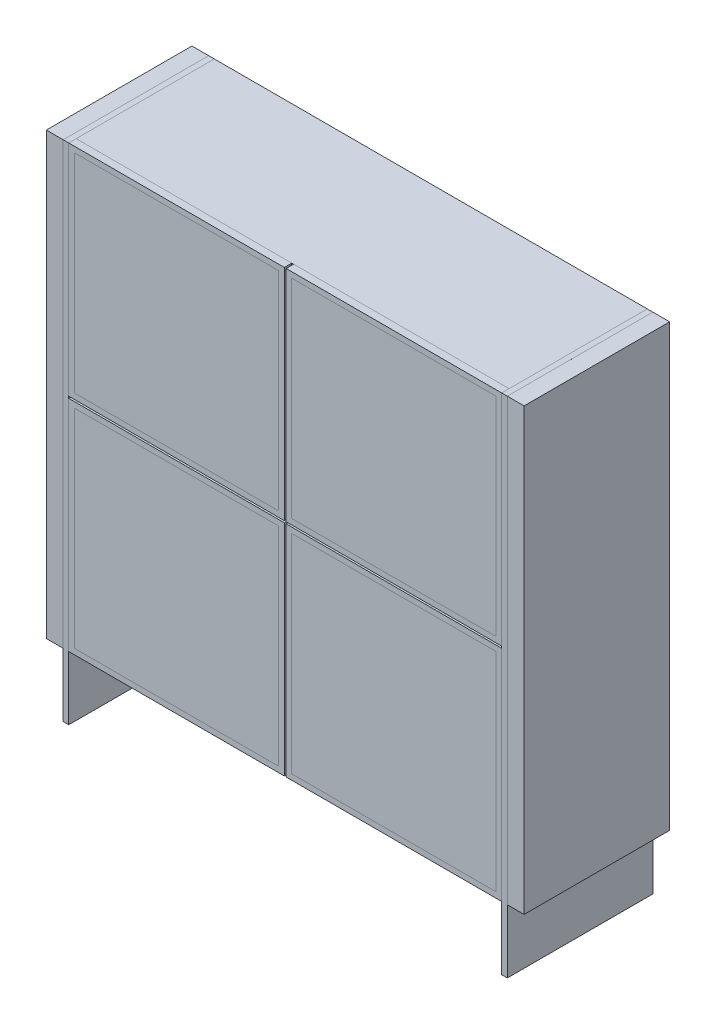
from build123d import *

# Parameters (mm, degrees)
CROQUIS1_W                     = 1160
CROQUIS1_H                     = 1180
SALIENTE_EXTRUIR1_DEPTH        = 370
VACIADO1_T                     = -10
CROQUIS1_4_W                   = 45
CROQUIS1_4_H                   = 1180
SALIENTE_EXTRUIR3_DEPTH        = 20
SALIENTE_EXTRUIR3_DEPTH_BACK   = 370
SALIENTE_EXTRUIR3_2_DEPTH      = 20
SALIENTE_EXTRUIR3_2_DEPTH_BACK = 370
CROQUIS2_W                     = 15
CROQUIS2_H                     = 1350
SALIENTE_EXTRUIR2_DEPTH        = 20
SALIENTE_EXTRUIR2_DEPTH_BACK   = 370
SALIENTE_EXTRUIR2_2_DEPTH      = 20
SALIENTE_EXTRUIR2_2_DEPTH_BACK = 370
CROQUIS3_W                     = 10
CROQUIS3_H                     = 1160
CROQUIS3_W_2                   = 1140
CROQUIS3_H_2                   = 10
SALIENTE_EXTRUIR4_DEPTH        = 360
SALIENTE_EXTRUIR5_START        = -20
CROQUIS4_W                     = 565
CROQUIS4_H                     = 10
SALIENTE_EXTRUIR5_DEPTH        = 340
SALIENTE_EXTRUIR5_2_DEPTH      = 340
SALIENTE_EXTRUIR5_3_DEPTH      = 340
SALIENTE_EXTRUIR5_4_DEPTH      = 340
CROQUIS5_W                     = 577.5
CROQUIS5_H                     = 587.5
CROQUIS5_W_2                   = 547.5
CROQUIS5_H_2                   = 557.5
SALIENTE_EXTRUIR6_DEPTH        = 20
SALIENTE_EXTRUIR6_2_DEPTH      = 20
SALIENTE_EXTRUIR6_3_DEPTH      = 20
SALIENTE_EXTRUIR6_4_DEPTH      = 20
SALIENTE_EXTRUIR7_START        = 10
CROQUIS5_2_W                   = 547.5
CROQUIS5_2_H                   = 557.5
SALIENTE_EXTRUIR7_DEPTH        = 10
SALIENTE_EXTRUIR7_2_DEPTH      = 10
SALIENTE_EXTRUIR7_3_DEPTH      = 10
SALIENTE_EXTRUIR7_4_DEPTH      = 10
CROQUIS6_W                     = 1160
CROQUIS6_H                     = 270
SALIENTE_EXTRUIR8_DEPTH        = 30


with BuildPart() as part:
    # Croquis1 → Saliente-Extruir1 (new body)
    with BuildSketch(Plane.XY):
        Rectangle(CROQUIS1_W, CROQUIS1_H)
    extrude(amount=-SALIENTE_EXTRUIR1_DEPTH)

    # Vaciado1
    vaciado1_openings = [part.faces().sort_by_distance(p)[0] for p in [
        (0, 0, 0),
    ]]
    offset(amount=VACIADO1_T, openings=vaciado1_openings, kind=Kind.INTERSECTION)


with BuildPart() as body_2:
    # Croquis1_4 → Saliente-Extruir3 (new body, two sides)
    with BuildSketch(Plane.XY) as saliente_extruir3_sk:
        with Locations((-617.5, 0)):
            Rectangle(CROQUIS1_4_W, CROQUIS1_4_H)
    extrude(amount=SALIENTE_EXTRUIR3_DEPTH)
    extrude(saliente_extruir3_sk.sketch, amount=-SALIENTE_EXTRUIR3_DEPTH_BACK)


with BuildPart() as body_3:
    # Croquis1_4 → Saliente-Extruir3 2 (new body, two sides)
    with BuildSketch(Plane.XY) as saliente_extruir3_2_sk:
        with Locations((617.5, 0)):
            Rectangle(CROQUIS1_4_W, CROQUIS1_4_H)
    extrude(amount=SALIENTE_EXTRUIR3_2_DEPTH)
    extrude(saliente_extruir3_2_sk.sketch, amount=-SALIENTE_EXTRUIR3_2_DEPTH_BACK)


with BuildPart() as body_4:
    # Croquis2 → Saliente-Extruir2 (new body, two sides)
    with BuildSketch(Plane.XY) as saliente_extruir2_sk:
        with Locations((-587.5, -85)):
            Rectangle(CROQUIS2_W, CROQUIS2_H)
    extrude(amount=SALIENTE_EXTRUIR2_DEPTH)
    extrude(saliente_extruir2_sk.sketch, amount=-SALIENTE_EXTRUIR2_DEPTH_BACK)


with BuildPart() as body_5:
    # Croquis2 → Saliente-Extruir2 2 (new body, two sides)
    with BuildSketch(Plane.XY) as saliente_extruir2_2_sk:
        with Locations((587.5, -85)):
            Rectangle(CROQUIS2_W, CROQUIS2_H)
    extrude(amount=SALIENTE_EXTRUIR2_2_DEPTH)
    extrude(saliente_extruir2_2_sk.sketch, amount=-SALIENTE_EXTRUIR2_2_DEPTH_BACK)


with BuildPart() as body_6:
    # Croquis3 → Saliente-Extruir4 (new body)
    with BuildSketch(Plane.XY):
        Rectangle(CROQUIS3_W, CROQUIS3_H)
        Rectangle(CROQUIS3_W_2, CROQUIS3_H_2)
    extrude(amount=-SALIENTE_EXTRUIR4_DEPTH)


with BuildPart() as body_7:
    # Croquis4 → Saliente-Extruir5 (new body)
    with BuildSketch(Plane.XY.offset(SALIENTE_EXTRUIR5_START)):
        with Locations((-287.5, 292.5)):
            Rectangle(CROQUIS4_W, CROQUIS4_H)
    extrude(amount=-SALIENTE_EXTRUIR5_DEPTH)


with BuildPart() as body_8:
    # Croquis4 → Saliente-Extruir5 2 (new body)
    with BuildSketch(Plane.XY.offset(SALIENTE_EXTRUIR5_START)):
        with Locations((287.5, 292.5)):
            Rectangle(CROQUIS4_W, CROQUIS4_H)
    extrude(amount=-SALIENTE_EXTRUIR5_2_DEPTH)


with BuildPart() as body_9:
    # Croquis4 → Saliente-Extruir5 3 (new body)
    with BuildSketch(Plane.XY.offset(SALIENTE_EXTRUIR5_START)):
        with Locations((287.5, -292.5)):
            Rectangle(CROQUIS4_W, CROQUIS4_H)
    extrude(amount=-SALIENTE_EXTRUIR5_3_DEPTH)


with BuildPart() as body_10:
    # Croquis4 → Saliente-Extruir5 4 (new body)
    with BuildSketch(Plane.XY.offset(SALIENTE_EXTRUIR5_START)):
        with Locations((-287.5, -292.5)):
            Rectangle(CROQUIS4_W, CROQUIS4_H)
    extrude(amount=-SALIENTE_EXTRUIR5_4_DEPTH)


with BuildPart() as body_11:
    # Croquis5 → Saliente-Extruir6 (new body)
    with BuildSketch(Plane.XY):
        with Locations((-291.25, -296.25)):
            Rectangle(CROQUIS5_W, CROQUIS5_H)
        with Locations((-291.25, -296.25)):
            Rectangle(CROQUIS5_W_2, CROQUIS5_H_2, mode=Mode.SUBTRACT)
    extrude(amount=SALIENTE_EXTRUIR6_DEPTH)


with BuildPart() as body_12:
    # Croquis5 → Saliente-Extruir6 2 (new body)
    with BuildSketch(Plane.XY):
        with Locations((-291.25, 296.25)):
            Rectangle(CROQUIS5_W, CROQUIS5_H)
        with Locations((-291.25, 296.25)):
            Rectangle(CROQUIS5_W_2, CROQUIS5_H_2, mode=Mode.SUBTRACT)
    extrude(amount=SALIENTE_EXTRUIR6_2_DEPTH)


with BuildPart() as body_13:
    # Croquis5 → Saliente-Extruir6 3 (new body)
    with BuildSketch(Plane.XY):
        with Locations((291.25, 296.25)):
            Rectangle(CROQUIS5_W, CROQUIS5_H)
        with Locations((291.25, 296.25)):
            Rectangle(CROQUIS5_W_2, CROQUIS5_H_2, mode=Mode.SUBTRACT)
    extrude(amount=SALIENTE_EXTRUIR6_3_DEPTH)


with BuildPart() as body_14:
    # Croquis5 → Saliente-Extruir6 4 (new body)
    with BuildSketch(Plane.XY):
        with Locations((291.25, -296.25)):
            Rectangle(CROQUIS5_W, CROQUIS5_H)
        with Locations((291.25, -296.25)):
            Rectangle(CROQUIS5_W_2, CROQUIS5_H_2, mode=Mode.SUBTRACT)
    extrude(amount=SALIENTE_EXTRUIR6_4_DEPTH)


with BuildPart() as body_15:
    # Croquis5_2 → Saliente-Extruir7 (new body)
    with BuildSketch(Plane.XY.offset(SALIENTE_EXTRUIR7_START)):
        with Locations((-291.25, 296.25)):
            Rectangle(CROQUIS5_2_W, CROQUIS5_2_H)
    extrude(amount=SALIENTE_EXTRUIR7_DEPTH)


with BuildPart() as body_16:
    # Croquis5_2 → Saliente-Extruir7 2 (new body)
    with BuildSketch(Plane.XY.offset(SALIENTE_EXTRUIR7_START)):
        with Locations((291.25, 296.25)):
            Rectangle(CROQUIS5_2_W, CROQUIS5_2_H)
    extrude(amount=SALIENTE_EXTRUIR7_2_DEPTH)


with BuildPart() as body_17:
    # Croquis5_2 → Saliente-Extruir7 3 (new body)
    with BuildSketch(Plane.XY.offset(SALIENTE_EXTRUIR7_START)):
        with Locations((-291.25, -296.25)):
            Rectangle(CROQUIS5_2_W, CROQUIS5_2_H)
    extrude(amount=SALIENTE_EXTRUIR7_3_DEPTH)


with BuildPart() as body_18:
    # Croquis5_2 → Saliente-Extruir7 4 (new body)
    with BuildSketch(Plane.XY.offset(SALIENTE_EXTRUIR7_START)):
        with Locations((291.25, -296.25)):
            Rectangle(CROQUIS5_2_W, CROQUIS5_2_H)
    extrude(amount=SALIENTE_EXTRUIR7_4_DEPTH)


with BuildPart() as body_19:
    # Croquis6 → Saliente-Extruir8 (new body)
    with BuildSketch(Plane.XZ.offset(590)):
        with Locations((0, -175)):
            Rectangle(CROQUIS6_W, CROQUIS6_H)
    extrude(amount=SALIENTE_EXTRUIR8_DEPTH)


solid = Compound([part.part, body_2.part, body_3.part, body_4.part, body_5.part, body_6.part, body_7.part, body_8.part, body_9.part, body_10.part, body_11.part, body_12.part, body_13.part, body_14.part, body_15.part, body_16.part, body_17.part, body_18.part, body_19.part])
